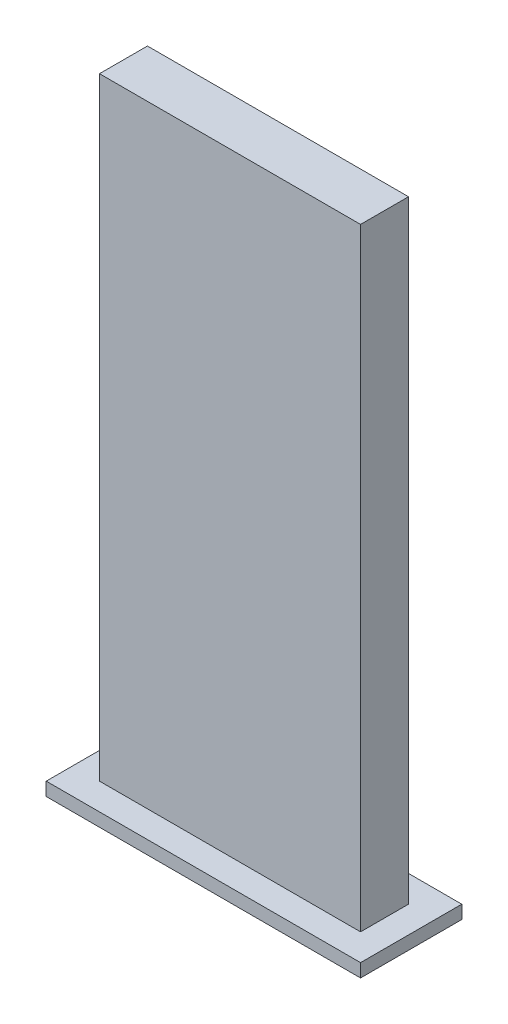
from build123d import *

# Parameters (mm, degrees)
SKETCH1_W           = 11.8
SKETCH1_H           = 3.8
BOSS_EXTRUDE1_DEPTH = 0.5
SKETCH2_W           = 9.8
SKETCH2_H           = 1.8
BOSS_EXTRUDE2_DEPTH = 23


with BuildPart() as part:
    # Sketch1 → Boss-Extrude1 (new body)
    with BuildSketch(Plane(origin=(0, 0, 0), x_dir=(1, 0, 0), z_dir=(0, 1, 0))):
        Rectangle(SKETCH1_W, SKETCH1_H)
    extrude(amount=BOSS_EXTRUDE1_DEPTH)

    # Sketch2 → Boss-Extrude2 (add)
    with BuildSketch(Plane(origin=(0, 0.5, 0), x_dir=(1, 0, 0), z_dir=(0, 1, 0))):
        Rectangle(SKETCH2_W, SKETCH2_H)
    extrude(amount=BOSS_EXTRUDE2_DEPTH)


solid = part.part
